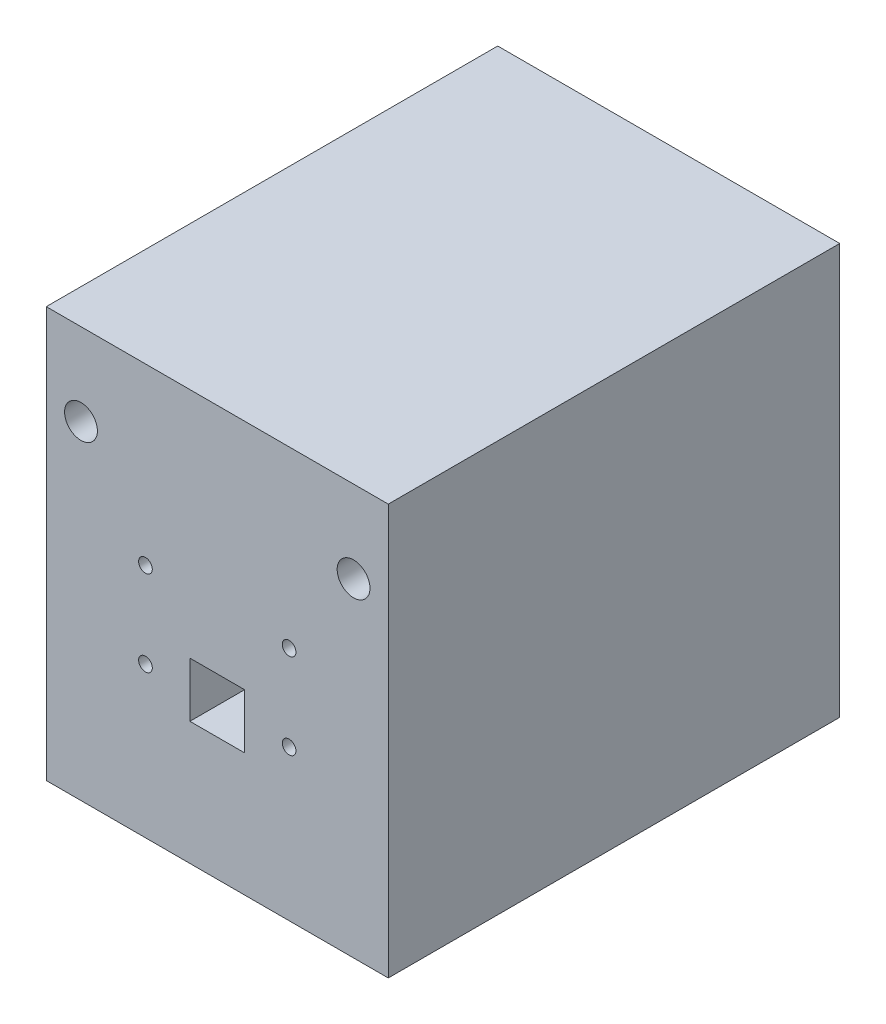
from build123d import *

# Parameters (mm, degrees)
SKETCH1_W           = 50
SKETCH1_H           = 60
SKETCH1_R           = 1
SKETCH1_R_2         = 2.4
SKETCH1_W_2         = 8
SKETCH1_H_2         = 8
BOSS_EXTRUDE1_DEPTH = 66


with BuildPart() as part:
    # Sketch1 → Boss-Extrude1 (new body)
    with BuildSketch(Plane.XY):
        with Locations((-11.874196976, 30)):
            Rectangle(SKETCH1_W, SKETCH1_H)
        with Locations((-22.374196976, 34.5)):
            Circle(SKETCH1_R, mode=Mode.SUBTRACT)
        with Locations((-22.374196976, 22)):
            Circle(SKETCH1_R, mode=Mode.SUBTRACT)
        with Locations((-1.374196976, 22)):
            Circle(SKETCH1_R, mode=Mode.SUBTRACT)
        with Locations((-1.374196976, 34.5)):
            Circle(SKETCH1_R, mode=Mode.SUBTRACT)
        with Locations((-31.799196976, 48)):
            Circle(SKETCH1_R_2, mode=Mode.SUBTRACT)
        with Locations((8.050803024, 48)):
            Circle(SKETCH1_R_2, mode=Mode.SUBTRACT)
        with Locations((-11.874196976, 22)):
            Rectangle(SKETCH1_W_2, SKETCH1_H_2, mode=Mode.SUBTRACT)
    extrude(amount=BOSS_EXTRUDE1_DEPTH)


solid = part.part
